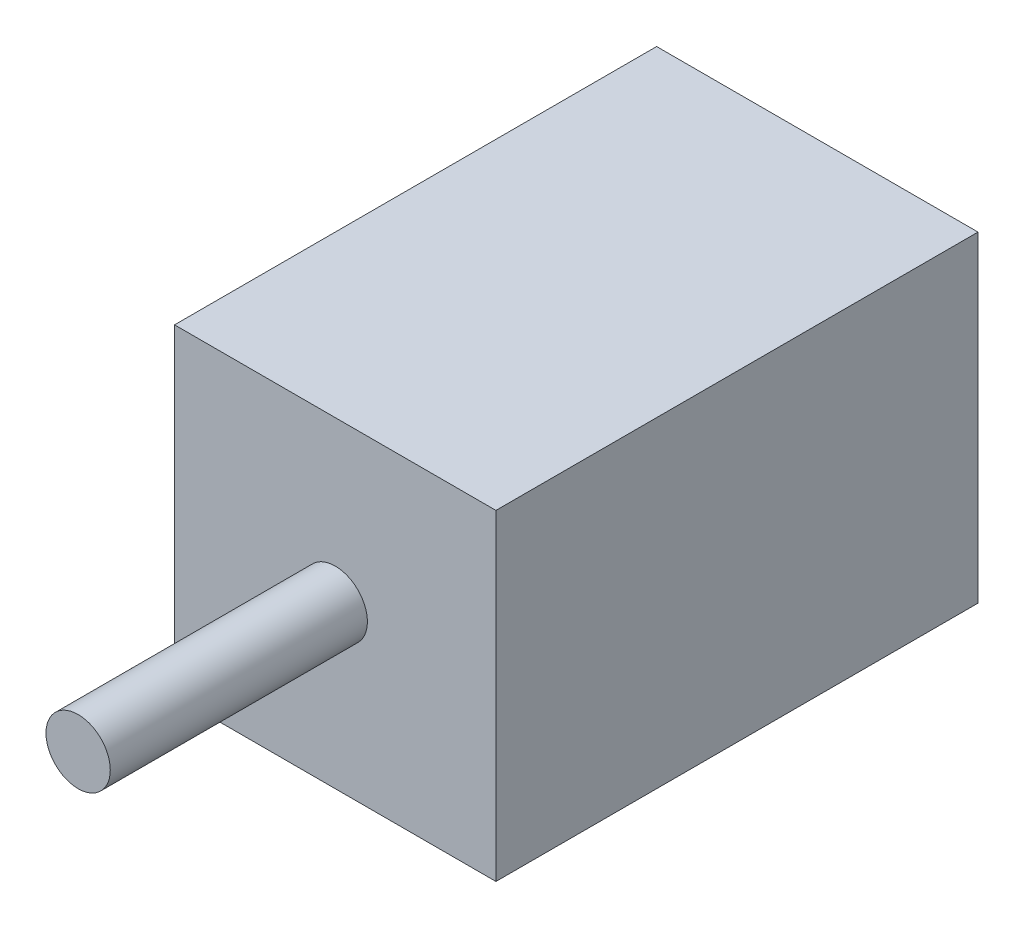
from build123d import *

# Parameters (mm, degrees)
IZIM1_W                     = 100
IZIM1_H                     = 100
Y_KSEKLIK_EKSTR_ZYON1_DEPTH = 150
IZIM2_R                     = 10
Y_KSEKLIK_EKSTR_ZYON2_DEPTH = 80


with BuildPart() as part:
    # Çizim1 → Yükseklik-Ekstrüzyon1 (new body)
    with BuildSketch(Plane.XY):
        with Locations((50, 50)):
            Rectangle(IZIM1_W, IZIM1_H)
    extrude(amount=Y_KSEKLIK_EKSTR_ZYON1_DEPTH)

    # Çizim2 → Yükseklik-Ekstrüzyon2 (add)
    with BuildSketch(Plane.XY.offset(150)):
        with Locations((50, 50)):
            Circle(IZIM2_R)
    extrude(amount=Y_KSEKLIK_EKSTR_ZYON2_DEPTH)


solid = part.part
